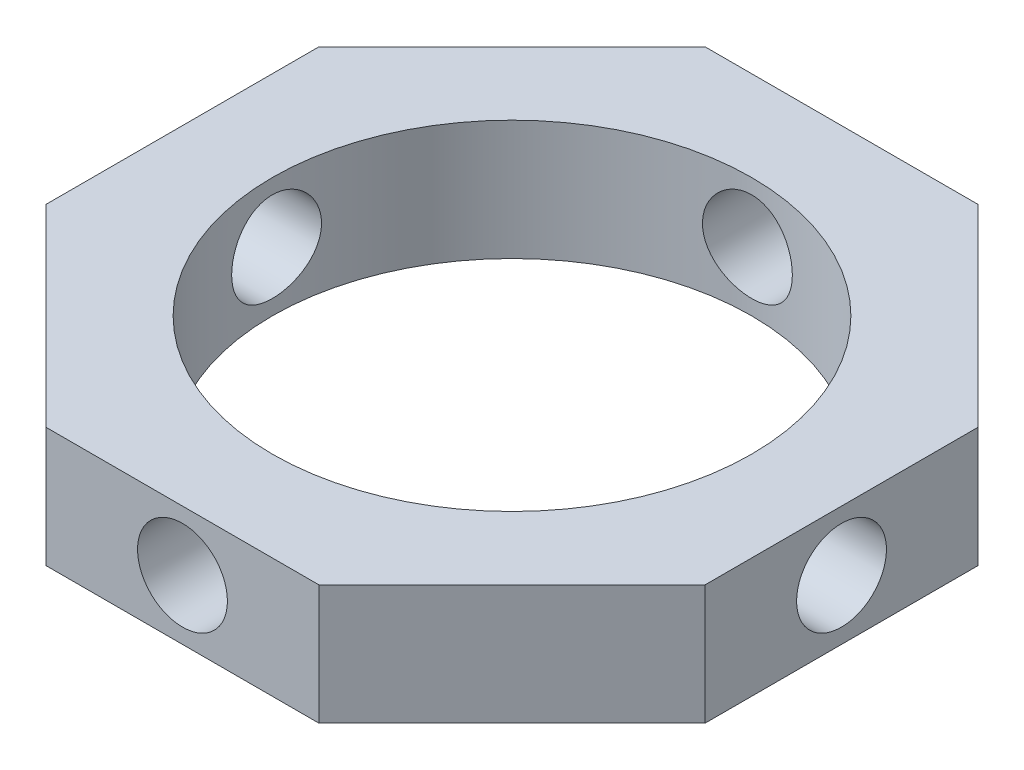
from build123d import *

# Parameters (mm, degrees)
SKETCH2_R           = 50.8
BOSS_EXTRUDE1_DEPTH = 25.4
SKETCH3_R           = 9.525
CUT_EXTRUDE1_DEPTH  = 140.7
SKETCH4_R           = 9.525
CUT_EXTRUDE2_DEPTH  = 140.7


with BuildPart() as part:
    # Sketch2 → Boss-Extrude1 (new body)
    with BuildSketch(Plane(origin=(0, 0, 0), x_dir=(1, 0, 0), z_dir=(0, 1, 0))):
        Polygon((69.85, 28.932817332), (28.932817332, 69.85), (-28.932817332, 69.85), (-69.85, 28.932817332), (-69.85, -28.932817332), (-28.932817332, -69.85), (28.932817332, -69.85), (69.85, -28.932817332), align=None)
        Circle(SKETCH2_R, mode=Mode.SUBTRACT)
    extrude(amount=BOSS_EXTRUDE1_DEPTH)

    # Sketch3 → Cut-Extrude1 (cut, through all)
    with BuildSketch(Plane.XY.offset(69.85)):
        with Locations((0, 12.7)):
            Circle(SKETCH3_R)
    extrude(amount=-CUT_EXTRUDE1_DEPTH, mode=Mode.SUBTRACT)

    # Sketch4 → Cut-Extrude2 (cut, through all)
    with BuildSketch(Plane.ZY.offset(69.85)):
        with Locations((0, 12.7)):
            Circle(SKETCH4_R)
    extrude(amount=-CUT_EXTRUDE2_DEPTH, mode=Mode.SUBTRACT)


solid = part.part
